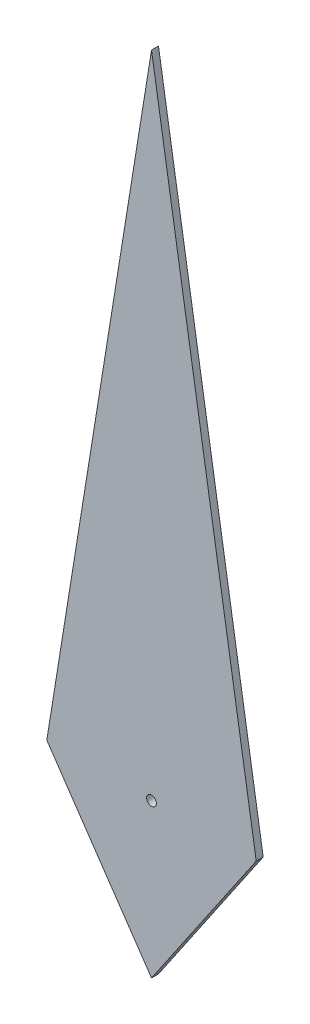
from build123d import *

# Parameters (mm, degrees)
SKETCH1_R           = 0.07
BOSS_EXTRUDE1_DEPTH = 0.1


with BuildPart() as part:
    # Sketch1 → Boss-Extrude1 (new body)
    with BuildSketch(Plane.XY):
        Polygon((0, 8.368960878), (1.5, -0.943040942), (0, -3.143469808), (-1.5, -0.943040942), align=None)
        with Locations((0, -0.943040942)):
            Circle(SKETCH1_R, mode=Mode.SUBTRACT)
    extrude(amount=BOSS_EXTRUDE1_DEPTH)


solid = part.part
